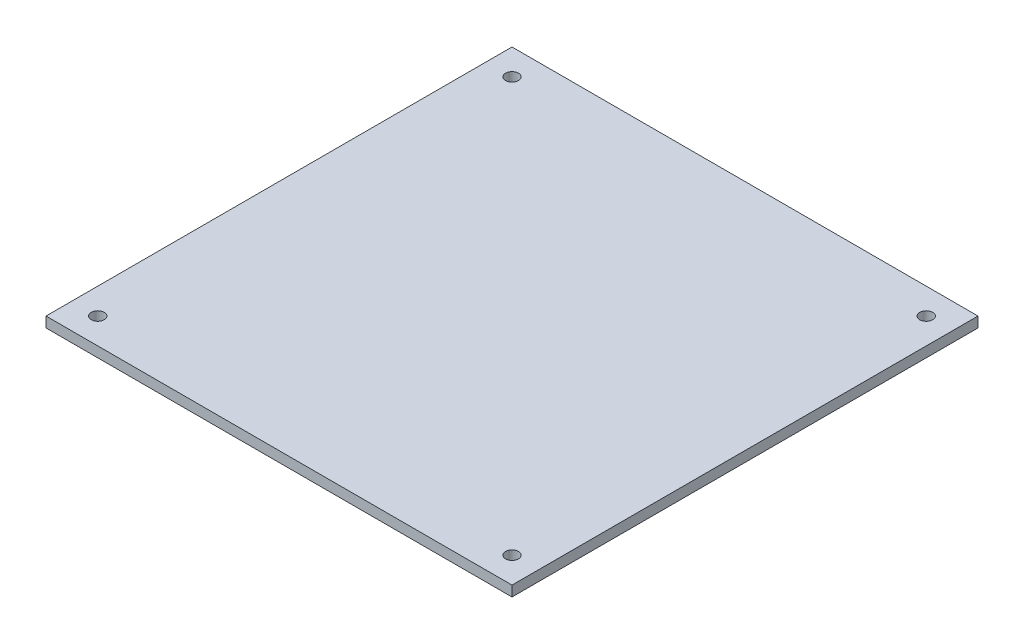
from build123d import *

# Parameters (mm, degrees)
SKETCH1_W             = 90
SKETCH1_H             = 90
BOSS_EXTRUDE1_DEPTH   = 2
M3X0_5_TAPPED_HOLE1_D = 2.5


with BuildPart() as part:
    # Sketch1 → Boss-Extrude1 (new body)
    with BuildSketch(Plane(origin=(0, 0, 0), x_dir=(1, 0, 0), z_dir=(0, 1, 0))):
        Rectangle(SKETCH1_W, SKETCH1_H)
    extrude(amount=BOSS_EXTRUDE1_DEPTH)

    # M3x0.5 Tapped Hole1 (through all)
    with Locations(Plane(origin=(0, 2, 0), x_dir=(1, 0, 0), z_dir=(0, 1, 0))):
        with Locations((-40, 40), (40, 40), (40, -40), (-40, -40)):
            Hole(M3X0_5_TAPPED_HOLE1_D / 2)


solid = part.part
